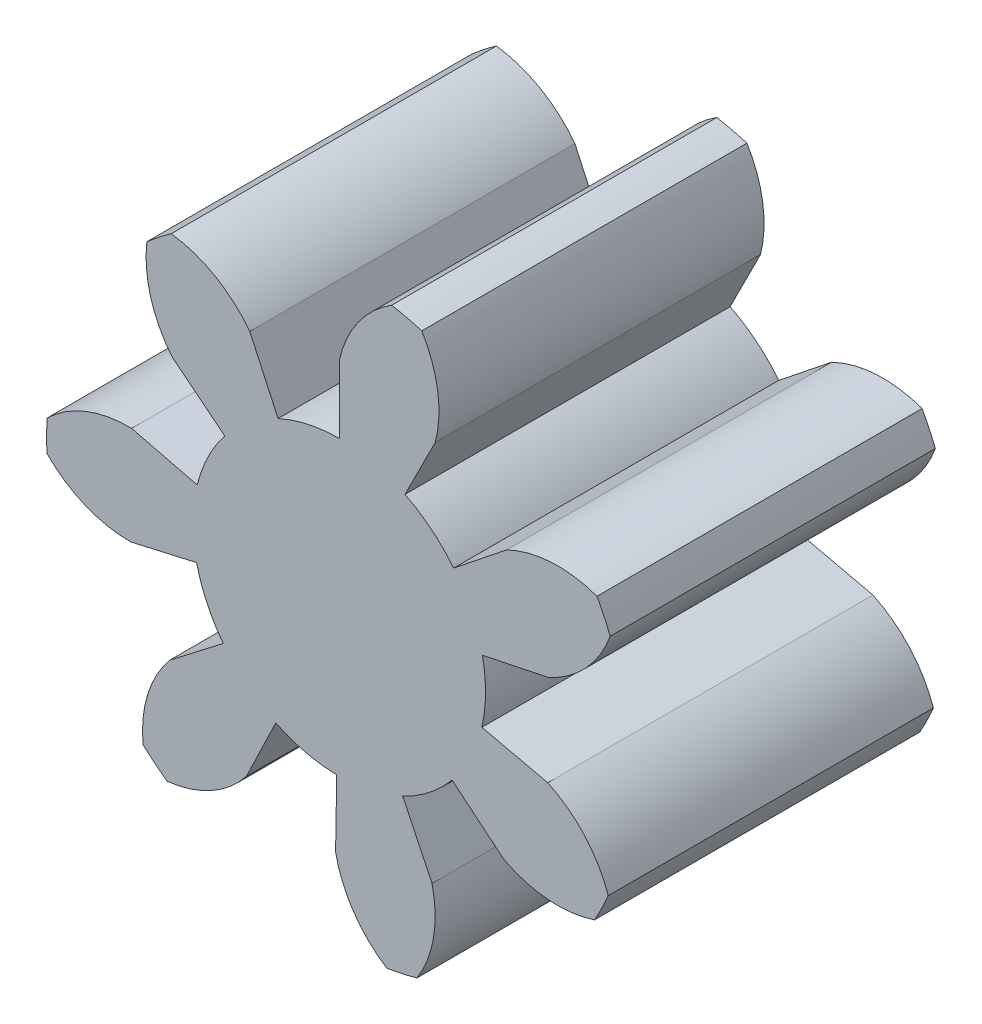
from build123d import *

# Parameters (mm, degrees)
BOSS_EXTRU_1_DEPTH           = 10
R_P_TITION_CIRCULAIRE2_COUNT = 7
ESQUISSE5_R                  = 4.5
BOSS_EXTRU_2_DEPTH           = 10


with BuildPart() as part:
    # Esquisse4 → Boss.-Extru.1 (new body)
    with BuildSketch(Plane.XY):
        with BuildLine():
            Line((0, 6.577848346), (0, 4.5))
            ThreePointArc((0, 4.5), (1.039097311, 4.378387463), (2.022031395, 4.020123013))
            Line((2.022031395, 4.020123013), (2.955692415, 5.876391002))
            ThreePointArc((2.955692415, 5.876391002), (3.02541978, 7.297456647), (2.538901994, 8.634464469))
            ThreePointArc((2.538901994, 8.634464469), (2.078194622, 8.756774927), (1.611657757, 8.854521968))
            ThreePointArc((1.611657757, 8.854521968), (0.576250392, 7.878703818), (0, 6.577848346))
        make_face()
    extrude(amount=BOSS_EXTRU_1_DEPTH)


with BuildPart() as r_p_tition_circulaire2_1:
    # Répétition circulaire2: pattern copy
    add(part.part.rotate(Axis((0, 0, 0), (0, 0, 1)), 1 * 360 / R_P_TITION_CIRCULAIRE2_COUNT))


with BuildPart() as r_p_tition_circulaire2_2:
    # Répétition circulaire2: pattern copy
    add(part.part.rotate(Axis((0, 0, 0), (0, 0, 1)), 2 * 360 / R_P_TITION_CIRCULAIRE2_COUNT))


with BuildPart() as r_p_tition_circulaire2_3:
    # Répétition circulaire2: pattern copy
    add(part.part.rotate(Axis((0, 0, 0), (0, 0, 1)), 3 * 360 / R_P_TITION_CIRCULAIRE2_COUNT))


with BuildPart() as r_p_tition_circulaire2_4:
    # Répétition circulaire2: pattern copy
    add(part.part.rotate(Axis((0, 0, 0), (0, 0, 1)), 4 * 360 / R_P_TITION_CIRCULAIRE2_COUNT))


with BuildPart() as r_p_tition_circulaire2_5:
    # Répétition circulaire2: pattern copy
    add(part.part.rotate(Axis((0, 0, 0), (0, 0, 1)), 5 * 360 / R_P_TITION_CIRCULAIRE2_COUNT))


with BuildPart() as r_p_tition_circulaire2_6:
    # Répétition circulaire2: pattern copy
    add(part.part.rotate(Axis((0, 0, 0), (0, 0, 1)), 6 * 360 / R_P_TITION_CIRCULAIRE2_COUNT))


with BuildPart() as part_1:
    add(part.part)

    add(r_p_tition_circulaire2_1.part)  # Boss.-Extru.2 merges Répétition circulaire2_1

    add(r_p_tition_circulaire2_2.part)  # Boss.-Extru.2 merges Répétition circulaire2_2

    add(r_p_tition_circulaire2_3.part)  # Boss.-Extru.2 merges Répétition circulaire2_3

    add(r_p_tition_circulaire2_4.part)  # Boss.-Extru.2 merges Répétition circulaire2_4

    add(r_p_tition_circulaire2_5.part)  # Boss.-Extru.2 merges Répétition circulaire2_5

    add(r_p_tition_circulaire2_6.part)  # Boss.-Extru.2 merges Répétition circulaire2_6
    # Esquisse5 → Boss.-Extru.2 (add)
    with BuildSketch(Plane.XY):
        Circle(ESQUISSE5_R)
    extrude(amount=BOSS_EXTRU_2_DEPTH)


solid = part_1.part
